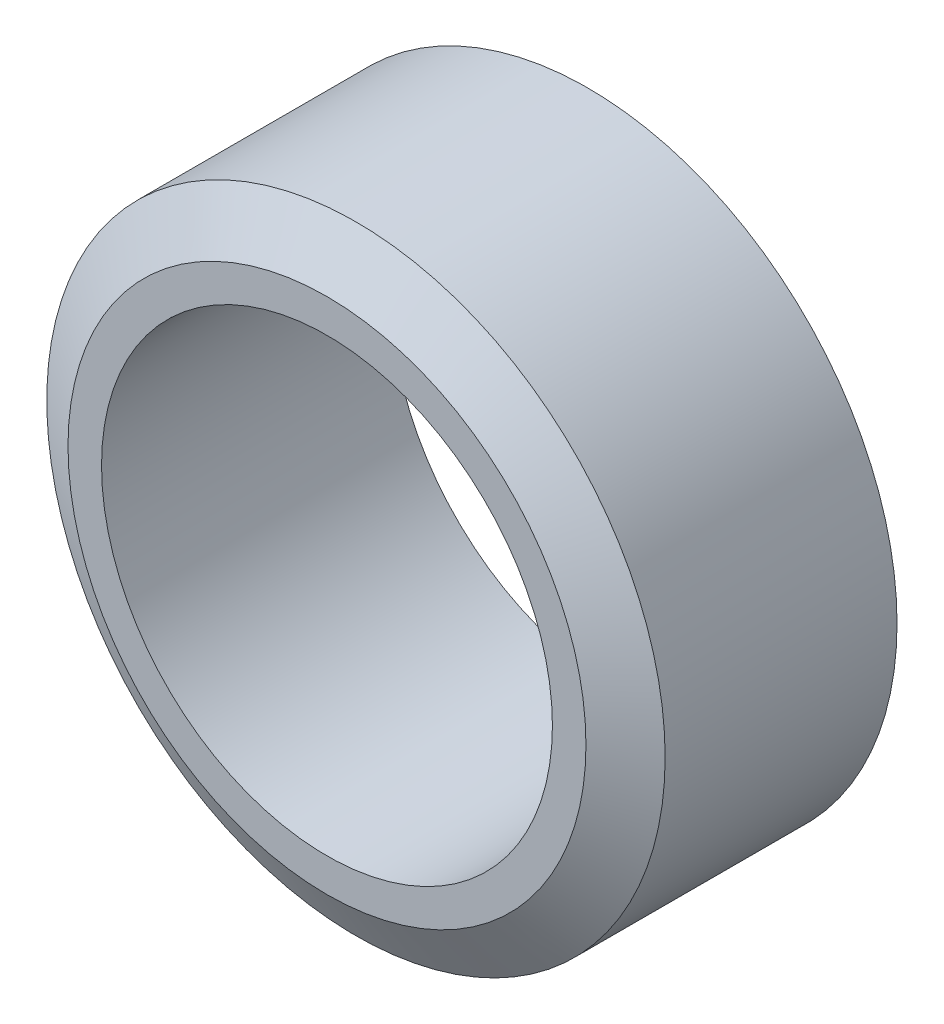
from build123d import *

# Parameters (mm, degrees)
ESQUISSE1_R        = 9.6
ESQUISSE1_R_2      = 7
BOSS_EXTRU_1_DEPTH = 9
CHANFREIN5_SIZE    = 0.9
CHANFREIN5_SIZE2   = 1.558845727
CHANFREIN9_SIZE    = 0.9
CHANFREIN9_SIZE2   = 1.558845727


with BuildPart() as part:
    # Esquisse1 → Boss.-Extru.1 (new body)
    with BuildSketch(Plane.XY):
        Circle(ESQUISSE1_R)
        Circle(ESQUISSE1_R_2, mode=Mode.SUBTRACT)
    extrude(amount=BOSS_EXTRU_1_DEPTH)

    # Chanfrein5
    chanfrein5_edges = [part.edges().sort_by_distance(p)[0] for p in [
        (-9.6, 0, 9),
    ]]
    chanfrein5_side = [part.faces().sort_by_distance(p)[0] for p in [
        (-9.6, 0, 4.5),
    ]]
    chamfer(chanfrein5_edges, length=CHANFREIN5_SIZE, length2=CHANFREIN5_SIZE2, reference=chanfrein5_side[0])

    # Chanfrein9
    chanfrein9_edges = [part.edges().sort_by_distance(p)[0] for p in [
        (-9.6, 0, 0),
    ]]
    chanfrein9_side = [part.faces().sort_by_distance(p)[0] for p in [
        (-9.6, 0, 4.05),
    ]]
    chamfer(chanfrein9_edges, length=CHANFREIN9_SIZE, length2=CHANFREIN9_SIZE2, reference=chanfrein9_side[0])


solid = part.part
